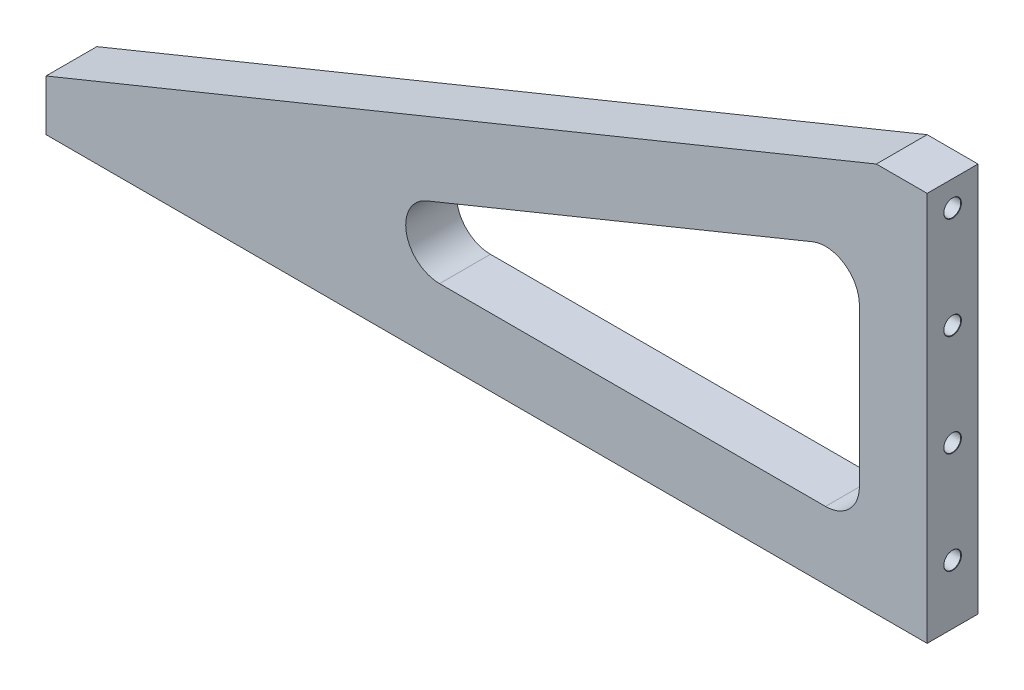
from build123d import *

# Parameters (mm, degrees)
BOSS_EXTRUDE1_DEPTH              = 9.525
F_1_4_20_TAPPED_HOLE3_AT_2_COUNT = 2
F_1_4_20_TAPPED_HOLE3_AT_2_PITCH = 38.1
F_1_4_20_TAPPED_HOLE3_AT_3_COUNT = 2
F_1_4_20_TAPPED_HOLE3_AT_3_PITCH = 76.2
F_1_4_20_TAPPED_HOLE3_AT_4_COUNT = 2
F_1_4_20_TAPPED_HOLE3_AT_4_PITCH = 114.3
F_1_4_20_TAPPED_HOLE2_AT_2_COUNT = 2
F_1_4_20_TAPPED_HOLE2_AT_2_PITCH = 76.2
F_1_4_20_TAPPED_HOLE2_AT_3_COUNT = 2
F_1_4_20_TAPPED_HOLE2_AT_3_PITCH = 152.4
F_1_4_20_TAPPED_HOLE2_AT_4_COUNT = 2
F_1_4_20_TAPPED_HOLE2_AT_4_PITCH = 228.6
F_1_4_20_TAPPED_HOLE2_AT_5_COUNT = 2
F_1_4_20_TAPPED_HOLE2_AT_5_PITCH = 304.8


with BuildPart() as part:
    # Sketch1 w/mock PCB → Boss-Extrude1 (new body, symmetric)
    with BuildSketch(Plane.XY):
        Polygon((-19.05, 148.59), (-330.2, 21.59), (-330.2, 2.54), (0, 2.54), (0, 148.59), align=None)
        with BuildLine():
            Line((-25.4, 99.663010652), (-25.4, 40.64))
            ThreePointArc((-25.4, 40.64), (-29.119743879, 31.659743879), (-38.1, 27.94))
            Line((-38.1, 27.94), (-182.706376097, 27.94))
            ThreePointArc((-182.706376097, 27.94), (-195.168718703, 38.194592718), (-187.505667965, 52.398265075))
            Line((-187.505667965, 52.398265075), (-42.899291867, 111.421275727))
            ThreePointArc((-42.899291867, 111.421275727), (-31.016957106, 110.20438169), (-25.4, 99.663010652))
        make_face(mode=Mode.SUBTRACT)
    extrude(amount=BOSS_EXTRUDE1_DEPTH, both=True)

    # Sketch6 → 1/4-20 Tapped Hole3 (revolve, cut)
    with BuildSketch(Plane(origin=(0, 139.065, 0), x_dir=(0, 0, -1), z_dir=(0, 1, 0))):
        Polygon((0, 0), (0, 20.583816902), (2.5527, 19.05), (2.5527, 17.78), (3.175, 17.78), (3.175, 0.127), (3.302, 0), align=None)
    f_1_4_20_tapped_hole3 = revolve(axis=Axis((6.35, 139.065, 0), (-1, 0, 0)), mode=Mode.SUBTRACT)

    # 1/4-20 Tapped Hole3 at 2: 1/4-20 Tapped Hole3 ×2
    with Locations(*[(0, -i * F_1_4_20_TAPPED_HOLE3_AT_2_PITCH, 0) for i in range(1, F_1_4_20_TAPPED_HOLE3_AT_2_COUNT)]):
        add(f_1_4_20_tapped_hole3, mode=Mode.SUBTRACT)

    # 1/4-20 Tapped Hole3 at 3: 1/4-20 Tapped Hole3 ×2
    with Locations(*[(0, -i * F_1_4_20_TAPPED_HOLE3_AT_3_PITCH, 0) for i in range(1, F_1_4_20_TAPPED_HOLE3_AT_3_COUNT)]):
        add(f_1_4_20_tapped_hole3, mode=Mode.SUBTRACT)

    # 1/4-20 Tapped Hole3 at 4: 1/4-20 Tapped Hole3 ×2
    with Locations(*[(0, -i * F_1_4_20_TAPPED_HOLE3_AT_4_PITCH, 0) for i in range(1, F_1_4_20_TAPPED_HOLE3_AT_4_COUNT)]):
        add(f_1_4_20_tapped_hole3, mode=Mode.SUBTRACT)

    # Sketch8 → 1/4-20 Tapped Hole2 (revolve, cut)
    with BuildSketch(Plane(origin=(-12.7, 2.54, 0), x_dir=(0, 0, -1), z_dir=(1, 0, 0))):
        Polygon((0, 0), (0, 20.583816902), (2.5527, 19.05), (2.5527, 17.78), (3.175, 17.78), (3.175, 0.127), (3.302, 0), align=None)
    f_1_4_20_tapped_hole2 = revolve(axis=Axis((-12.7, -3.81, 0), (0, 1, 0)), mode=Mode.SUBTRACT)

    # 1/4-20 Tapped Hole2 at 2: 1/4-20 Tapped Hole2 ×2
    with Locations(*[(-i * F_1_4_20_TAPPED_HOLE2_AT_2_PITCH, 0, 0) for i in range(1, F_1_4_20_TAPPED_HOLE2_AT_2_COUNT)]):
        add(f_1_4_20_tapped_hole2, mode=Mode.SUBTRACT)

    # 1/4-20 Tapped Hole2 at 3: 1/4-20 Tapped Hole2 ×2
    with Locations(*[(-i * F_1_4_20_TAPPED_HOLE2_AT_3_PITCH, 0, 0) for i in range(1, F_1_4_20_TAPPED_HOLE2_AT_3_COUNT)]):
        add(f_1_4_20_tapped_hole2, mode=Mode.SUBTRACT)

    # 1/4-20 Tapped Hole2 at 4: 1/4-20 Tapped Hole2 ×2
    with Locations(*[(-i * F_1_4_20_TAPPED_HOLE2_AT_4_PITCH, 0, 0) for i in range(1, F_1_4_20_TAPPED_HOLE2_AT_4_COUNT)]):
        add(f_1_4_20_tapped_hole2, mode=Mode.SUBTRACT)

    # 1/4-20 Tapped Hole2 at 5: 1/4-20 Tapped Hole2 ×2
    with Locations(*[(-i * F_1_4_20_TAPPED_HOLE2_AT_5_PITCH, 0, 0) for i in range(1, F_1_4_20_TAPPED_HOLE2_AT_5_COUNT)]):
        add(f_1_4_20_tapped_hole2, mode=Mode.SUBTRACT)


solid = part.part
